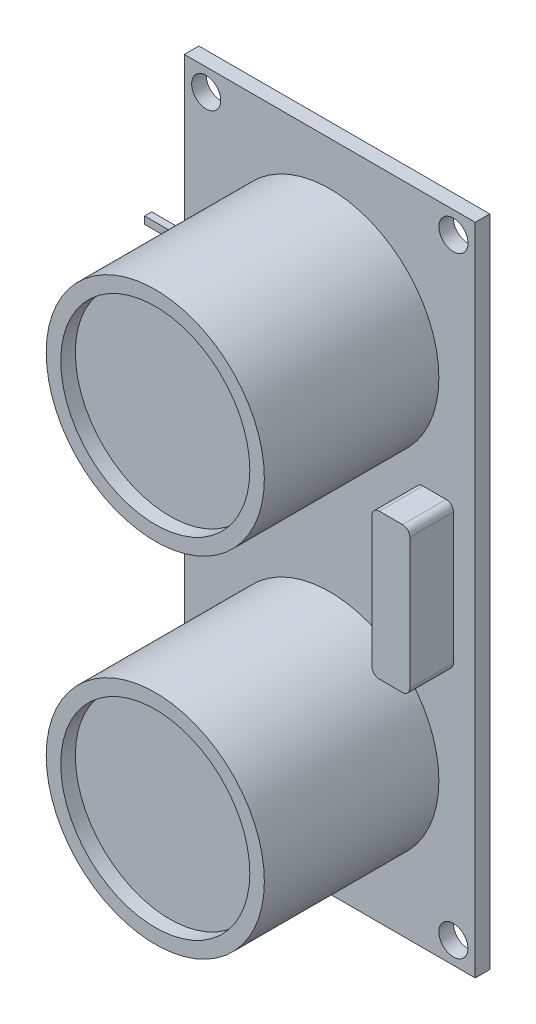
from build123d import *

# Parameters (mm, degrees)
SKETCH1_W           = 20
SKETCH1_H           = 45
BOSS_EXTRUDE1_DEPTH = 1
SKETCH2_R           = 7.5
BOSS_EXTRUDE2_DEPTH = 12
SKETCH3_R           = 6.5
CUT_EXTRUDE1_DEPTH  = 1
SKETCH4_W           = 2.6
SKETCH4_H           = 10
BOSS_EXTRUDE3_DEPTH = 3
FILLET1_R           = 0.5
SKETCH5_W           = 3
SKETCH5_H           = 15
BOSS_EXTRUDE4_DEPTH = 3
SKETCH6_W           = 0.5
SKETCH6_H           = 0.5
BOSS_EXTRUDE5_DEPTH = 3
SKETCH7_W           = 0.490041207
SKETCH7_H           = 0.5
BOSS_EXTRUDE6_DEPTH = 12
SKETCH8_R           = 1
CUT_EXTRUDE2_DEPTH  = 3


with BuildPart() as part:
    # Sketch1 → Boss-Extrude1 (new body)
    with BuildSketch(Plane.XY):
        with Locations((-12.292244857, -79.882705913)):
            Rectangle(SKETCH1_W, SKETCH1_H)
    extrude(amount=BOSS_EXTRUDE1_DEPTH)

    # Sketch2 → Boss-Extrude2 (add)
    with BuildSketch(Plane.XY.offset(1)):
        with Locations((-12.292244857, -67.882705913)):
            Circle(SKETCH2_R)
        with Locations((-12.292244857, -91.882705913)):
            Circle(SKETCH2_R)
    extrude(amount=BOSS_EXTRUDE2_DEPTH)

    # Sketch3 → Cut-Extrude1 (cut)
    with BuildSketch(Plane.XY.offset(13)):
        with Locations((-12.292244857, -67.882705913)):
            Circle(SKETCH3_R)
        with Locations((-12.292244857, -91.882705913)):
            Circle(SKETCH3_R)
    extrude(amount=-CUT_EXTRUDE1_DEPTH, mode=Mode.SUBTRACT)

    # Sketch4 → Boss-Extrude3 (add)
    with BuildSketch(Plane.XY.offset(1)):
        with Locations((-5.092244857, -79.882705913)):
            Rectangle(SKETCH4_W, SKETCH4_H)
    extrude(amount=BOSS_EXTRUDE3_DEPTH)

    # Fillet1
    fillet1_edges = [part.edges().sort_by_distance(p)[0] for p in [
        (-6.392244857, -74.882705913, 2.5),
        (-6.392244857, -84.882705913, 2.5),
        (-3.792244857, -84.882705913, 2.5),
        (-3.792244857, -74.882705913, 2.5),
    ]]
    fillet(fillet1_edges, radius=FILLET1_R)

    # Sketch5 → Boss-Extrude4 (add)
    with BuildSketch(Plane(origin=(0, 0, 0), x_dir=(-1, 0, 0), z_dir=(0, 0, -1))):
        with Locations((19.292244857, -79.882705913)):
            Rectangle(SKETCH5_W, SKETCH5_H)
    extrude(amount=BOSS_EXTRUDE4_DEPTH)

    # Sketch6 → Boss-Extrude5 (add)
    with BuildSketch(Plane(origin=(0, 0, -3), x_dir=(-1, 0, 0), z_dir=(0, 0, -1))):
        with Locations((19.292244857, -84.632705913)):
            Rectangle(SKETCH6_W, SKETCH6_H)
        with Locations((19.292244857, -81.632705913)):
            Rectangle(SKETCH6_W, SKETCH6_H)
        with Locations((19.292244857, -78.132705913)):
            Rectangle(SKETCH6_W, SKETCH6_H)
        with Locations((19.292244857, -75.132705913)):
            Rectangle(SKETCH6_W, SKETCH6_H)
    extrude(amount=BOSS_EXTRUDE5_DEPTH)

    # Sketch7 → Boss-Extrude6 (add)
    with BuildSketch(Plane.ZY.offset(19.542244857)):
        with Locations((-5.754979396, -75.132705913)):
            Rectangle(SKETCH7_W, SKETCH7_H)
        with Locations((-5.754979396, -78.132705913)):
            Rectangle(SKETCH7_W, SKETCH7_H)
        with Locations((-5.754979396, -81.632705913)):
            Rectangle(SKETCH7_W, SKETCH7_H)
        with Locations((-5.754979396, -84.632705913)):
            Rectangle(SKETCH7_W, SKETCH7_H)
    extrude(amount=BOSS_EXTRUDE6_DEPTH)

    # Sketch8 → Cut-Extrude2 (cut)
    with BuildSketch(Plane.XY.offset(1)):
        with Locations((-20.792244857, -58.882705913)):
            Circle(SKETCH8_R)
        with Locations((-3.792244857, -58.882705913)):
            Circle(SKETCH8_R)
        with Locations((-3.792244857, -100.882705913)):
            Circle(SKETCH8_R)
        with Locations((-20.792244857, -100.882705913)):
            Circle(SKETCH8_R)
    extrude(amount=-CUT_EXTRUDE2_DEPTH, mode=Mode.SUBTRACT)


solid = part.part
